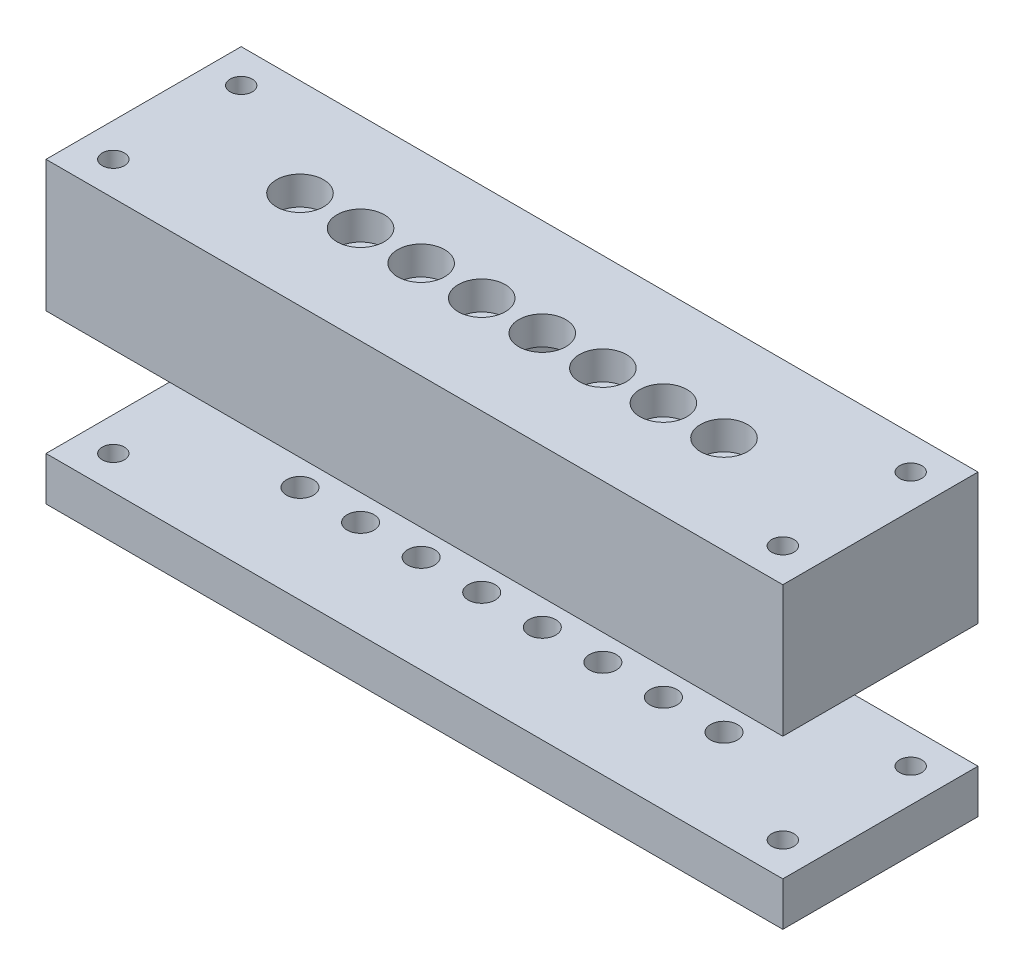
from build123d import *

# Parameters (mm, degrees)
BOSS_EXTRUDE1_DEPTH     = 14.5
LPATTERN1_COUNT         = 8
LPATTERN1_PITCH         = 9
CUT_EXTRUDE1_START      = -14.5
SKETCH4_W               = 42
SKETCH4_H               = 4
CUT_EXTRUDE1_DEPTH      = 25
CUT_EXTRUDE2_START      = -14.5
SKETCH5_W               = 109.48
SKETCH5_H               = 18.35
CUT_EXTRUDE2_DEPTH      = 30
SKETCH6_R               = 1.65
CUT_EXTRUDE3_DEPTH      = 1
CUT_EXTRUDE3_DEPTH_BACK = 45.35


with BuildPart() as part:
    # Sketch1 → Boss-Extrude1 (new body, symmetric)
    with BuildSketch(Plane.XY):
        Polygon((-54.74, -22.175), (-34.225, -22.175), (-34.225, -20.675), (-33.5, -20.675), (-33.5, -17.675), (-33.5, -15.675), (-33.5, 2.675), (-33.5, 4.675), (-34.5, 4.675), (-34.5, 9.675), (-35, 9.675), (-35, 22.175), (-54.74, 22.175), align=None)
        Polygon((-34.225, -22.175), (54.74, -22.175), (54.74, 22.175), (-35, 22.175), (-35, 9.675), (-34.5, 9.675), (-34.5, 4.675), (-33.5, 4.675), (-33.5, 2.675), (-33.5, -15.675), (-33.5, -17.675), (-33.5, -20.675), (-34.225, -20.675), align=None)
    extrude(amount=BOSS_EXTRUDE1_DEPTH, both=True)

    # Sketch3 → Cut-Revolve1 (revolve, cut)
    with BuildSketch(Plane.XY):
        Polygon((-34.225, -22.175), (-34.225, -20.675), (-33.5, -20.675), (-33.5, -17.675), (-33.5, -15.675), (-33.5, 2.675), (-33.5, 4.675), (-34.5, 4.675), (-34.5, 9.675), (-35, 9.675), (-35, 22.175), (-31.5, 22.175), (-31.5, -22.175), align=None)
    cut_revolve1 = revolve(axis=Axis((-31.5, 22.175, 0), (0, -1, 0)), mode=Mode.SUBTRACT)

    # LPattern1: Cut-Revolve1 ×8
    with Locations(*[(i * LPATTERN1_PITCH, 0, 0) for i in range(1, LPATTERN1_COUNT)]):
        add(cut_revolve1, mode=Mode.SUBTRACT)

    # Sketch4 → Cut-Extrude1 (cut)
    with BuildSketch(Plane.XY.offset(CUT_EXTRUDE1_START)):
        with Locations((-21.75, 15.925)):
            Rectangle(SKETCH4_W, SKETCH4_H)
        with Locations((21.75, 15.925)):
            Rectangle(SKETCH4_W, SKETCH4_H)
    extrude(amount=CUT_EXTRUDE1_DEPTH, mode=Mode.SUBTRACT)

    # Sketch5 → Cut-Extrude2 (cut, through all)
    with BuildSketch(Plane.XY.offset(CUT_EXTRUDE2_START)):
        with Locations((0, -6.5)):
            Rectangle(SKETCH5_W, SKETCH5_H)
    extrude(amount=CUT_EXTRUDE2_DEPTH, mode=Mode.SUBTRACT)

    # Sketch6 → Cut-Extrude3 (cut, two sides)
    with BuildSketch(Plane(origin=(0, 22.175, 0), x_dir=(1, 0, 0), z_dir=(0, 1, 0))) as cut_extrude3_sk:
        with Locations((-49.74, 9.5)):
            Circle(SKETCH6_R)
        with Locations((49.74, 9.5)):
            Circle(SKETCH6_R)
        with Locations((49.74, -9.5)):
            Circle(SKETCH6_R)
        with Locations((-49.74, -9.5)):
            Circle(SKETCH6_R)
    extrude(amount=CUT_EXTRUDE3_DEPTH, mode=Mode.SUBTRACT)
    extrude(cut_extrude3_sk.sketch, amount=-CUT_EXTRUDE3_DEPTH_BACK, mode=Mode.SUBTRACT)


solid = part.part
